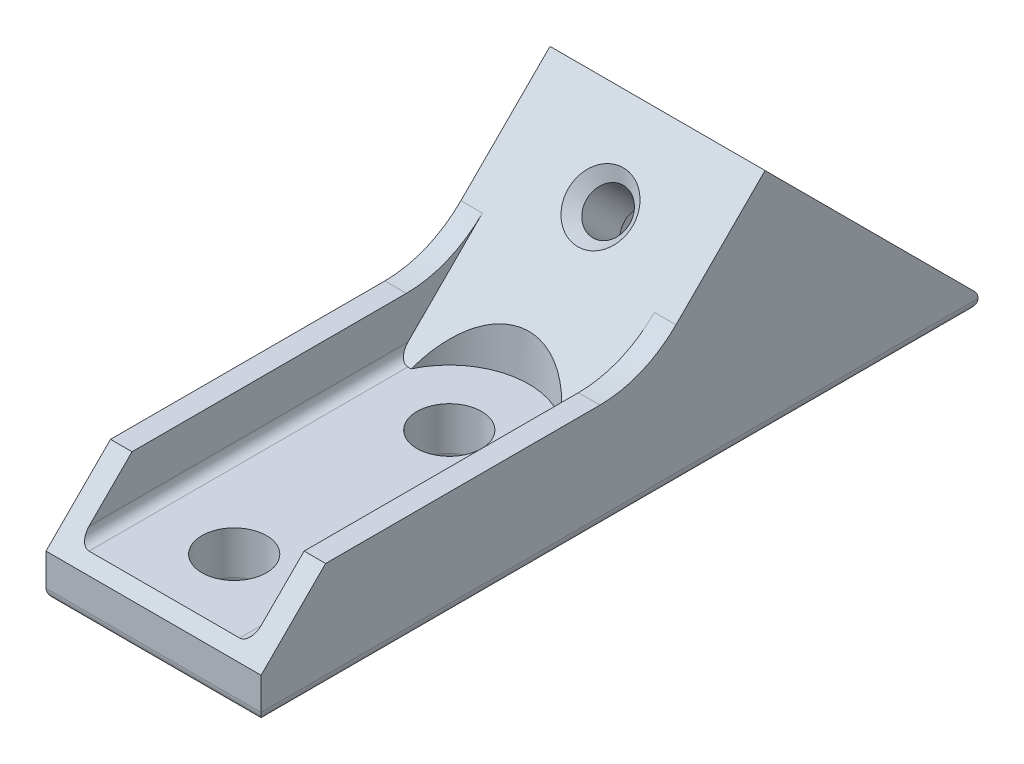
from build123d import *

# Parameters (mm, degrees)
SKETCH1_W           = 20
SKETCH1_H           = 40
BOSS_EXTRUDE1_DEPTH = 5
BOSS_EXTRUDE2_DEPTH = 20
SKETCH3_R           = 3
CUT_EXTRUDE1_DEPTH  = 15
LPATTERN1_COUNT     = 2
LPATTERN1_PITCH     = 20
SKETCH4_R           = 7.4
CUT_EXTRUDE2_DEPTH  = 15
SKETCH5_R           = 2
CUT_EXTRUDE3_DEPTH  = 50
CUT_EXTRUDE4_START  = -6
CUT_EXTRUDE4_DEPTH  = 40
CHAMFER1_SIZE       = 1
FILLET2_R           = 1
SKETCH7_W           = 2
SKETCH7_H           = 45.940909218
BOSS_EXTRUDE3_DEPTH = 5
LPATTERN2_COUNT     = 2
LPATTERN2_PITCH     = 18
FILLET3_R           = 1
CHAMFER2_SIZE       = 6
FILLET4_R           = 10


with BuildPart() as part:
    # Sketch1 → Boss-Extrude1 (new body)
    with BuildSketch(Plane(origin=(0, 0, 0), x_dir=(1, 0, 0), z_dir=(0, 1, 0))):
        Rectangle(SKETCH1_W, SKETCH1_H)
    extrude(amount=BOSS_EXTRUDE1_DEPTH)

    # Sketch2 → Boss-Extrude2 (add)
    with BuildSketch(Plane.ZY.offset(10)):
        Polygon((-5.650883497, 0), (-26.864086932, 21.213203436), (-48.077290368, 0), align=None)
    extrude(amount=-BOSS_EXTRUDE2_DEPTH)

    # Sketch3 → Cut-Extrude1 (cut)
    with BuildSketch(Plane(origin=(0, 5, 0), x_dir=(1, 0, 0), z_dir=(0, 1, 0))):
        with Locations((0, -12.5)):
            Circle(SKETCH3_R)
    cut_extrude1 = extrude(amount=-CUT_EXTRUDE1_DEPTH, mode=Mode.SUBTRACT)

    # LPattern1: Cut-Extrude1 ×2
    with Locations(*[(0, 0, -i * LPATTERN1_PITCH) for i in range(1, LPATTERN1_COUNT)]):
        add(cut_extrude1, mode=Mode.SUBTRACT)

    # Sketch4 → Cut-Extrude2 (cut)
    with BuildSketch(Plane(origin=(0, 5, 0), x_dir=(1, 0, 0), z_dir=(0, 1, 0))):
        with Locations((0, 7.5)):
            Circle(SKETCH4_R)
    extrude(amount=CUT_EXTRUDE2_DEPTH, mode=Mode.SUBTRACT)

    # Sketch5 → Cut-Extrude3 (cut)
    with BuildSketch(Plane(origin=(0, -2.825441748, -2.825441748), x_dir=(1, 0, 0), z_dir=(0, 0.707106781, 0.707106781))):
        with Locations((0, 26.49577804)):
            Circle(SKETCH5_R)
    extrude(amount=-CUT_EXTRUDE3_DEPTH, mode=Mode.SUBTRACT)

    # Sketch6 → Cut-Extrude4 (cut)
    with BuildSketch(Plane(origin=(0, -2.825441748, -2.825441748), x_dir=(1, 0, 0), z_dir=(0, 0.707106781, 0.707106781)).offset(CUT_EXTRUDE4_START)):
        Polygon((0, 30.24855479), (-3.25, 28.372166415), (-3.25, 24.619389665), (0, 22.743001291), (3.25, 24.619389665), (3.25, 28.372166415), align=None)
    extrude(amount=-CUT_EXTRUDE4_DEPTH, mode=Mode.SUBTRACT)

    # Chamfer1
    chamfer1_edges = [part.edges().sort_by_distance(p)[0] for p in [
        (-2, 15.909902577, -21.560786074),
    ]]
    chamfer(chamfer1_edges, length=CHAMFER1_SIZE)

    # Fillet2
    fillet2_edges = [part.edges().sort_by_distance(p)[0] for p in [
        (0, 0, -48.077290368),
        (-3, 0, 12.5),
        (-3, 0, -7.5),
        (0, 0, 20),
        (-10, 0, -14.038645184),
        (-1.625, 0, -41.451109482),
        (-3.25, 0, -37.47068865),
        (-1.625, 0, -33.490267818),
        (1.625, 0, -33.490267818),
        (3.25, 0, -37.47068865),
        (1.625, 0, -41.451109482),
        (10, 0, -14.038645184),
    ]]
    fillet(fillet2_edges, radius=FILLET2_R)

    # Sketch7 → Boss-Extrude3 (add)
    with BuildSketch(Plane(origin=(0, 5, 0), x_dir=(1, 0, 0), z_dir=(0, 1, 0))):
        with Locations((-9, 2.970454609)):
            Rectangle(SKETCH7_W, SKETCH7_H)
    boss_extrude3 = extrude(amount=BOSS_EXTRUDE3_DEPTH)

    # LPattern2: Boss-Extrude3 ×2
    with Locations(*[(i * LPATTERN2_PITCH, 0, 0) for i in range(1, LPATTERN2_COUNT)]):
        add(boss_extrude3)

    # Fillet3
    fillet3_edges = [part.edges().sort_by_distance(p)[0] for p in [
        (-8, 5, 4.674558252),
        (8, 5, 4.674558252),
    ]]
    fillet(fillet3_edges, radius=FILLET3_R)

    # Chamfer2
    chamfer2_edges = [part.edges().sort_by_distance(p)[0] for p in [
        (9, 10, 20),
    ]]
    chamfer(chamfer2_edges, length=CHAMFER2_SIZE)

    # Fillet4
    fillet4_edges = [part.edges().sort_by_distance(p)[0] for p in [
        (-9, 10, -15.650883497),
        (9, 10, -15.650883497),
    ]]
    fillet(fillet4_edges, radius=FILLET4_R)


solid = part.part
